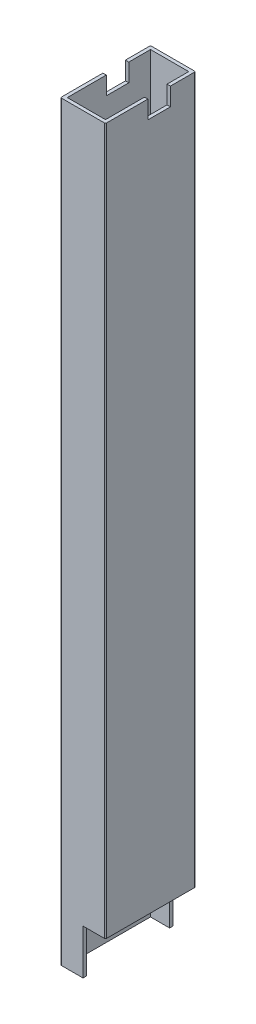
from build123d import *

# Parameters (mm, degrees)
SKETCH1_W           = 17
SKETCH1_H           = 37
BOSS_EXTRUDE1_DEPTH = 334
SKETCH2_W           = 10
SKETCH2_H           = 20
CUT_EXTRUDE1_DEPTH  = 40
SKETCH4_W           = 10
SKETCH4_H           = 8
CUT_EXTRUDE3_DEPTH  = 337.980711614


with BuildPart() as part:
    # Sketch1 → Boss-Extrude1 (new body)
    with BuildSketch(Plane(origin=(0, 0, 0), x_dir=(1, 0, 0), z_dir=(0, 1, 0))):
        with BuildLine():
            Line((0.5, 0), (19.5, 0))
            ThreePointArc((19.5, 0), (19.853553391, 0.146446609), (20, 0.5))
            Line((20, 0.5), (20, 39.5))
            ThreePointArc((20, 39.5), (19.853553391, 39.853553391), (19.5, 40))
            Line((19.5, 40), (0.5, 40))
            ThreePointArc((0.5, 40), (0.146446609, 39.853553391), (0, 39.5))
            Line((0, 39.5), (0, 0.5))
            ThreePointArc((0, 0.5), (0.146446609, 0.146446609), (0.5, 0))
        make_face()
        with Locations((10, 20)):
            Rectangle(SKETCH1_W, SKETCH1_H, mode=Mode.SUBTRACT)
    extrude(amount=BOSS_EXTRUDE1_DEPTH)

    # Sketch2 → Cut-Extrude1 (cut)
    with BuildSketch(Plane.XY):
        with Locations((15, 10)):
            Rectangle(SKETCH2_W, SKETCH2_H)
    extrude(amount=-CUT_EXTRUDE1_DEPTH, mode=Mode.SUBTRACT)

    # Sketch4 → Cut-Extrude3 (cut, through all)
    with BuildSketch(Plane(origin=(20, 0, 0), x_dir=(0, 0, -1), z_dir=(1, 0, 0))):
        with Locations((23.84, 330)):
            Rectangle(SKETCH4_W, SKETCH4_H)
    extrude(amount=-CUT_EXTRUDE3_DEPTH, mode=Mode.SUBTRACT)


solid = part.part
